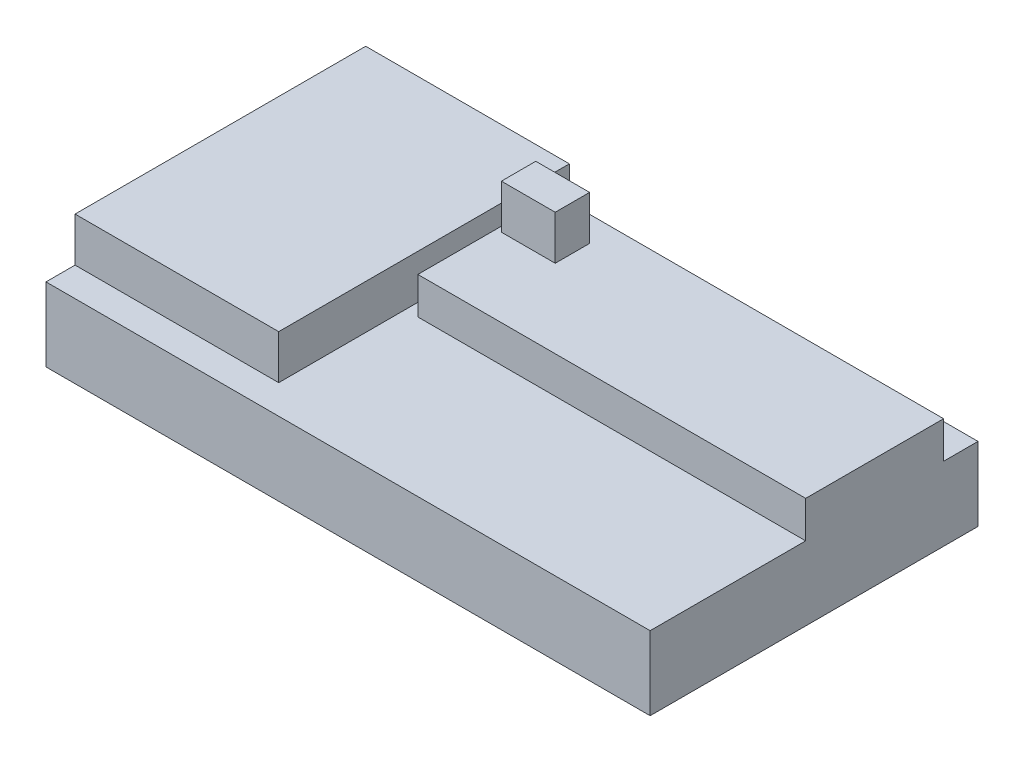
from build123d import *

# Parameters (mm, degrees)
SKETCH1_W           = 82
SKETCH1_H           = 44.5
BOSS_EXTRUDE1_DEPTH = 10
SKETCH2_W           = 52.638055151
SKETCH2_H           = 18.722088721
BOSS_EXTRUDE2_DEPTH = 5
SKETCH3_W           = 27.641719578
SKETCH3_H           = 39.450206574
BOSS_EXTRUDE3_DEPTH = 6
SKETCH4_W           = 7.307754503
SKETCH4_H           = 4.667726012
BOSS_EXTRUDE4_DEPTH = 6


with BuildPart() as part:
    # Sketch1 → Boss-Extrude1 (new body)
    with BuildSketch(Plane(origin=(0, 0, 0), x_dir=(1, 0, 0), z_dir=(0, 1, 0))):
        with Locations((1.955938697, 0.340996169)):
            Rectangle(SKETCH1_W, SKETCH1_H)
    extrude(amount=BOSS_EXTRUDE1_DEPTH)

    # Sketch2 → Boss-Extrude2 (add)
    with BuildSketch(Plane(origin=(0, 10, 0), x_dir=(1, 0, 0), z_dir=(0, 1, 0))):
        with Locations((16.636911121, 8.563535134)):
            Rectangle(SKETCH2_W, SKETCH2_H)
    extrude(amount=BOSS_EXTRUDE2_DEPTH)

    # Sketch3 → Boss-Extrude3 (add)
    with BuildSketch(Plane(origin=(0, 10, 0), x_dir=(1, 0, 0), z_dir=(0, 1, 0))):
        with Locations((-25.223201514, 1.759430562)):
            Rectangle(SKETCH3_W, SKETCH3_H)
    extrude(amount=BOSS_EXTRUDE3_DEPTH)

    # Sketch4 → Boss-Extrude4 (add)
    with BuildSketch(Plane(origin=(0, 15, 0), x_dir=(1, 0, 0), z_dir=(0, 1, 0))):
        with Locations((-5.326444236, 12.169741761)):
            Rectangle(SKETCH4_W, SKETCH4_H)
    extrude(amount=BOSS_EXTRUDE4_DEPTH)


solid = part.part
